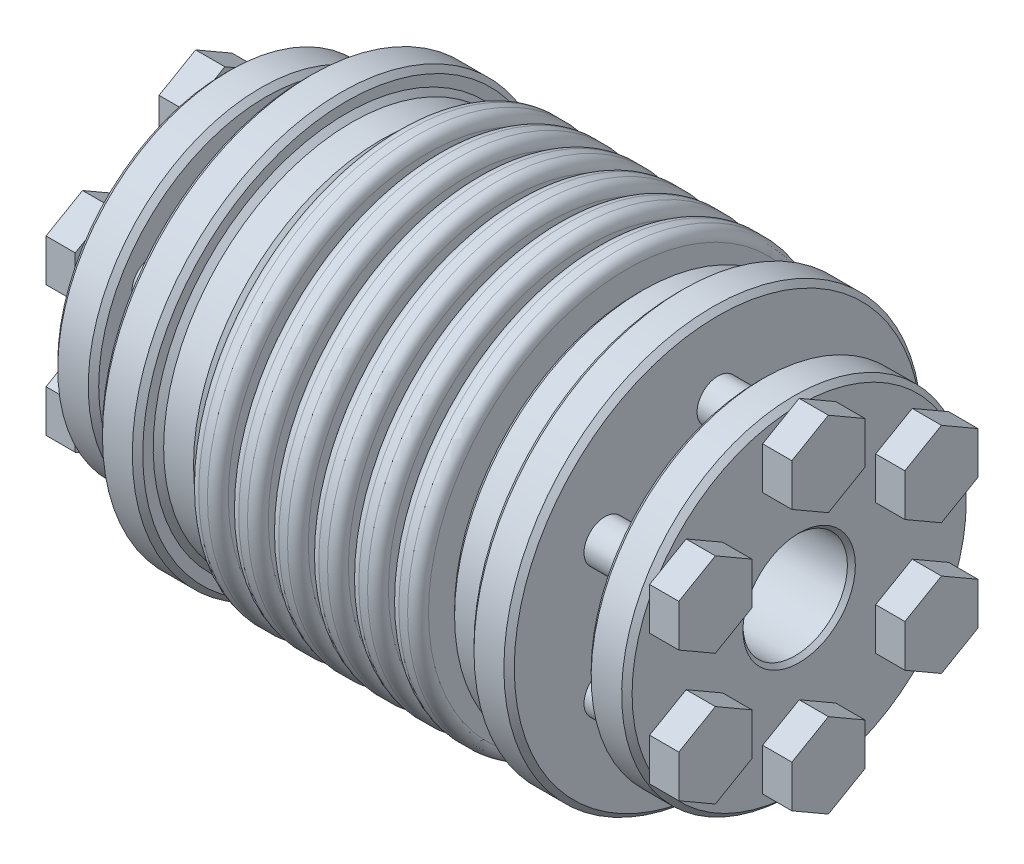
from build123d import *

# Parameters (mm, degrees)
SKETCH1_R                      = 20
BOSS_EXTRUDE1_DEPTH            = 27.5
SKETCH2_R                      = 5
CUT_EXTRUDE1_DEPTH             = 19
CHAMFER1_SIZE                  = 0.381
CUT_EXTRUDE2_REACH             = 29.5
SKETCH5_R                      = 12.6905
CUT_EXTRUDE2_DIRECTION_2_REACH = 29.5
SKETCH8_W                      = 1
SKETCH8_H                      = 5.3095
FILLET1_R                      = 1
FILLET2_R                      = 0.25
BOSS_EXTRUDE2_DEPTH            = 2.8
BOSS_EXTRUDE2_2_DEPTH          = 2.8
BOSS_EXTRUDE2_3_DEPTH          = 2.8
BOSS_EXTRUDE2_4_DEPTH          = 2.8
BOSS_EXTRUDE2_5_DEPTH          = 2.8
BOSS_EXTRUDE2_6_DEPTH          = 2.8
SKETCH11_R                     = 2
BOSS_EXTRUDE3_DEPTH            = 10.579774
CHAMFER2_SIZE                  = 0.5


with BuildPart() as part:
    # Sketch1 → Boss-Extrude1 (new body, symmetric)
    with BuildSketch(Plane(origin=(0, 0, 0), x_dir=(0, 0, -1), z_dir=(1, 0, 0))):
        Circle(SKETCH1_R)
    extrude(amount=BOSS_EXTRUDE1_DEPTH, both=True)

    # Sketch2 → Cut-Extrude1 (cut)
    with BuildSketch(Plane(origin=(27.5, 0, 0), x_dir=(0, 0, -1), z_dir=(1, 0, 0))):
        Circle(SKETCH2_R)
    cut_extrude1 = extrude(amount=-CUT_EXTRUDE1_DEPTH, mode=Mode.SUBTRACT)

    # Mirror3: Cut-Extrude1 across plane
    add(cut_extrude1.mirror(Plane(origin=(0, 0, 0), x_dir=(0, 0, 1), z_dir=(1, 0, 0))), mode=Mode.SUBTRACT)

    # Chamfer1
    chamfer1_edges = [part.edges().sort_by_distance(p)[0] for p in [
        (-27.5, 0, 20),
        (27.5, 0, 20),
        (27.5, 0, 5),
        (-27.5, 0, 5),
    ]]
    chamfer(chamfer1_edges, length=CHAMFER1_SIZE)

    # Cut-Extrude2: up to this face of the body (flat: up to its plane)
    cut_extrude2_end = Plane(part.part.faces().sort_by_distance((-8.5, 0, 0))[0])
    # Sketch5 → Cut-Extrude2 (cut, up to the picked face)
    with BuildSketch(Plane(origin=(0, 0, 0), x_dir=(0, 0, -1), z_dir=(1, 0, 0)), mode=Mode.PRIVATE) as cut_extrude2_sk1:
        Circle(SKETCH5_R)
    cut_extrude2_tool1 = split(extrude(cut_extrude2_sk1.sketch, amount=-CUT_EXTRUDE2_REACH, mode=Mode.PRIVATE), bisect_by=cut_extrude2_end, keep=Keep.BOTH, mode=Mode.PRIVATE)
    add(cut_extrude2_tool1.solids().sort_by(Axis((0, 0, 0), (-1, 0, 0)))[0], mode=Mode.SUBTRACT)

    # Cut-Extrude2 direction 2: up to this face of the body (flat: up to its plane)
    cut_extrude2_direction_2_end = Plane(part.part.faces().sort_by_distance((8.5, 0, 0))[0])
    # Sketch5 → Cut-Extrude2 direction 2 (cut, up to the picked face)
    with BuildSketch(Plane(origin=(0, 0, 0), x_dir=(0, 0, -1), z_dir=(1, 0, 0)), mode=Mode.PRIVATE) as cut_extrude2_direction_2_sk1:
        Circle(SKETCH5_R)
    cut_extrude2_direction_2_tool1 = split(extrude(cut_extrude2_direction_2_sk1.sketch, amount=CUT_EXTRUDE2_DIRECTION_2_REACH, mode=Mode.PRIVATE), bisect_by=cut_extrude2_direction_2_end, keep=Keep.BOTH, mode=Mode.PRIVATE)
    add(cut_extrude2_direction_2_tool1.solids().sort_by(Axis((0, 0, 0), (1, 0, 0)))[0], mode=Mode.SUBTRACT)

    # Sketch8 → Cut-Revolve1 (revolve, cut)
    with BuildSketch(Plane(origin=(0, 0, 0), x_dir=(1, 0, 0), z_dir=(0, 1, 0)), mode=Mode.PRIVATE) as cut_revolve1_sk:
        with Locations((0, 17.34525)):
            Rectangle(SKETCH8_W, SKETCH8_H)
        with Locations((3.833333333, 17.34525)):
            Rectangle(SKETCH8_W, SKETCH8_H)
        with Locations((7.666666667, 17.34525)):
            Rectangle(SKETCH8_W, SKETCH8_H)
        with Locations((11.5, 17.34525)):
            Rectangle(SKETCH8_W, SKETCH8_H)
    cut_revolve1 = revolve(cut_revolve1_sk.sketch.rotate(Axis((0, 0, 0), (1, 0, 0)), 180), axis=Axis((0, 0, 0), (1, 0, 0)), mode=Mode.SUBTRACT)  # turned: the seam where the file's is

    # Mirror2: Cut-Revolve1 across plane
    add(cut_revolve1.mirror(Plane(origin=(0, 0, 0), x_dir=(0, 0, 1), z_dir=(1, 0, 0))), mode=Mode.SUBTRACT)

    # Fillet1
    fillet1_edges = [part.edges().sort_by_distance(p)[0] for p in [
        (-0.5, 0, 20),
        (0.5, 0, 20),
        (11, 0, 20),
        (12, 0, 20),
        (3.333333333, 0, 20),
        (4.333333333, 0, 20),
        (7.166666667, 0, 20),
        (8.166666667, 0, 20),
        (-12, 0, 20),
        (-11, 0, 20),
        (-3.333333333, 0, 20),
        (-4.333333333, 0, 20),
        (-7.166666667, 0, 20),
        (-8.166666667, 0, 20),
    ]]
    fillet(fillet1_edges, radius=FILLET1_R)

    # Fillet2
    fillet2_edges = [part.edges().sort_by_distance(p)[0] for p in [
        (0.5, 0, -14.6905),
        (-0.5, 0, -14.6905),
        (12, 0, -14.6905),
        (11, 0, -14.6905),
        (4.333333333, 0, -14.6905),
        (3.333333333, 0, -14.6905),
        (8.166666667, 0, -14.6905),
        (7.166666667, 0, -14.6905),
        (-12, 0, -14.6905),
        (-11, 0, -14.6905),
        (-3.333333333, 0, -14.6905),
        (-4.333333333, 0, -14.6905),
        (-7.166666667, 0, -14.6905),
        (-8.166666667, 0, -14.6905),
    ]]
    fillet(fillet2_edges, radius=FILLET2_R)

    # Sketch9 → Cut-Revolve2 (revolve, cut)
    with BuildSketch(Plane.XY, mode=Mode.PRIVATE) as cut_revolve2_sk:
        Polygon((12, 18), (15.860112884, 18), (15.860112884, 20), (19.720225768, 20), (19.720225768, 7.81935795), (23.580338653, 8.5), (23.580338653, 16.5), (27.5, 16.5), (27.5, 25), (12, 25), align=None)
        Polygon((-12, 25), (-12, 18), (-15.860112884, 18), (-15.860112884, 20), (-19.720225768, 20), (-19.720225768, 7.81935795), (-23.580338653, 8.5), (-23.580338653, 16.5), (-27.5, 16.5), (-27.5, 25), align=None)
    revolve(cut_revolve2_sk.sketch.rotate(Axis((27.5, 0, 0), (-1, 0, 0)), 270), axis=Axis((27.5, 0, 0), (-1, 0, 0)), mode=Mode.SUBTRACT)  # turned: the seam where the file's is

    # Chamfer2
    chamfer2_edges = [part.edges().sort_by_distance(p)[0] for p in [
        (12, 0, -18),
        (15.860112884, 0, -18),
        (15.860112884, 0, 20),
        (19.720225768, 0, 20),
        (23.580338653, 0, -16.5),
        (27.5, 0, -16.5),
        (-23.580338653, 0, -16.5),
        (-27.5, 0, -16.5),
        (-12, 0, -18),
        (-15.860112884, 0, -18),
        (-15.860112884, 0, 20),
        (-19.720225768, 0, 20),
    ]]
    chamfer(chamfer2_edges, length=CHAMFER2_SIZE)


with BuildPart() as body_2:
    # Sketch10 → Boss-Extrude2 (new body)
    with BuildSketch(Plane(origin=(27.5, 0, 0), x_dir=(0, 0, -1), z_dir=(1, 0, 0))):
        Polygon((7.325317547, 4.229274058), (10.825317547, 2.208548116), (14.325317547, 4.229274058), (14.325317547, 8.270725942), (10.825317547, 10.291451884), (7.325317547, 8.270725942), align=None)
    extrude(amount=BOSS_EXTRUDE2_DEPTH)


with BuildPart() as body_3:
    # Sketch10 → Boss-Extrude2 2 (new body)
    with BuildSketch(Plane(origin=(27.5, 0, 0), x_dir=(0, 0, -1), z_dir=(1, 0, 0))):
        Polygon((0, 8.458548116), (3.5, 10.479274058), (3.5, 14.520725942), (0, 16.541451884), (-3.5, 14.520725942), (-3.5, 10.479274058), align=None)
    extrude(amount=BOSS_EXTRUDE2_2_DEPTH)


    add(body_2.part)  # Boss-Extrude3 merges body 2


with BuildPart() as body_4:
    # Sketch10 → Boss-Extrude2 3 (new body)
    with BuildSketch(Plane(origin=(27.5, 0, 0), x_dir=(0, 0, -1), z_dir=(1, 0, 0))):
        Polygon((7.325317547, -4.229274058), (7.325317547, -8.270725942), (10.825317547, -10.291451884), (14.325317547, -8.270725942), (14.325317547, -4.229274058), (10.825317547, -2.208548116), align=None)
    extrude(amount=BOSS_EXTRUDE2_3_DEPTH)


with BuildPart() as body_5:
    # Sketch10 → Boss-Extrude2 4 (new body)
    with BuildSketch(Plane(origin=(27.5, 0, 0), x_dir=(0, 0, -1), z_dir=(1, 0, 0))):
        Polygon((0, -8.458548116), (-3.5, -10.479274058), (-3.5, -14.520725942), (0, -16.541451884), (3.5, -14.520725942), (3.5, -10.479274058), align=None)
    extrude(amount=BOSS_EXTRUDE2_4_DEPTH)


with BuildPart() as body_6:
    # Sketch10 → Boss-Extrude2 5 (new body)
    with BuildSketch(Plane(origin=(27.5, 0, 0), x_dir=(0, 0, -1), z_dir=(1, 0, 0))):
        Polygon((-7.325317547, -4.229274058), (-10.825317547, -2.208548116), (-14.325317547, -4.229274058), (-14.325317547, -8.270725942), (-10.825317547, -10.291451884), (-7.325317547, -8.270725942), align=None)
    extrude(amount=BOSS_EXTRUDE2_5_DEPTH)


with BuildPart() as body_7:
    # Sketch10 → Boss-Extrude2 6 (new body)
    with BuildSketch(Plane(origin=(27.5, 0, 0), x_dir=(0, 0, -1), z_dir=(1, 0, 0))):
        Polygon((-7.325317547, 4.229274058), (-7.325317547, 8.270725942), (-10.825317547, 10.291451884), (-14.325317547, 8.270725942), (-14.325317547, 4.229274058), (-10.825317547, 2.208548116), align=None)
    extrude(amount=BOSS_EXTRUDE2_6_DEPTH)


with BuildPart() as body_3_1:
    add(body_3.part)

    add(body_4.part)  # Boss-Extrude3 merges body 4

    add(body_5.part)  # Boss-Extrude3 merges body 5

    add(body_6.part)  # Boss-Extrude3 merges body 6

    add(body_7.part)  # Boss-Extrude3 merges body 7
    # Sketch11 → Boss-Extrude3 (add)
    with BuildSketch(Plane(origin=(30.3, 0, 0), x_dir=(0, 0, -1), z_dir=(1, 0, 0))):
        with Locations((0, 12.5)):
            Circle(SKETCH11_R)
        with Locations((10.825317547, 6.25)):
            Circle(SKETCH11_R)
        with Locations((10.825317547, -6.25)):
            Circle(SKETCH11_R)
        with Locations((0, -12.5)):
            Circle(SKETCH11_R)
        with Locations((-10.825317547, -6.25)):
            Circle(SKETCH11_R)
        with Locations((-10.825317547, 6.25)):
            Circle(SKETCH11_R)
    extrude(amount=-BOSS_EXTRUDE3_DEPTH)


with BuildPart() as body_3_2:
    # Mirror5: mirrored copy
    add(body_3_1.part.mirror(Plane(origin=(0, 0, 0), x_dir=(0, 0, 1), z_dir=(1, 0, 0))))


solid = Compound([part.part, body_3_1.part, body_3_2.part])
